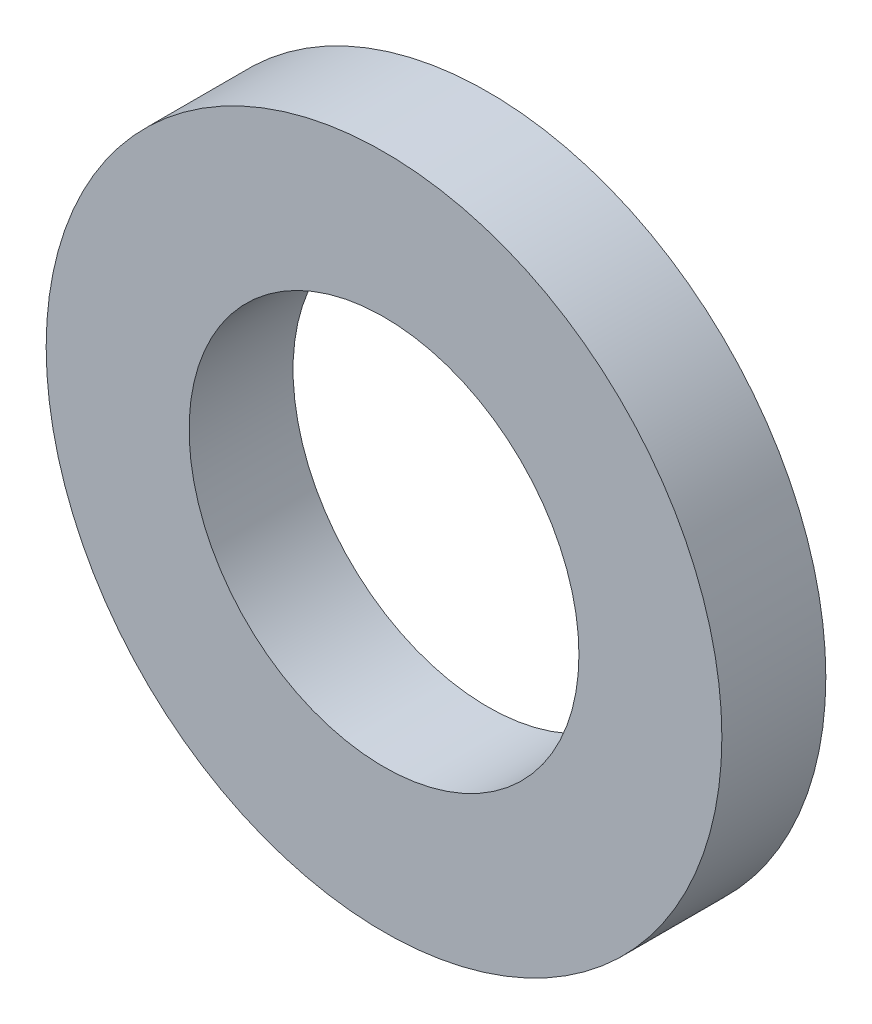
from build123d import *

# Parameters (mm, degrees)
SKETCH1_R           = 13
SKETCH1_R_2         = 7.5
BOSS_EXTRUDE1_DEPTH = 4


with BuildPart() as part:
    # Sketch1 → Boss-Extrude1 (new body)
    with BuildSketch(Plane.XY):
        Circle(SKETCH1_R)
        Circle(SKETCH1_R_2, mode=Mode.SUBTRACT)
    extrude(amount=BOSS_EXTRUDE1_DEPTH)


solid = part.part
